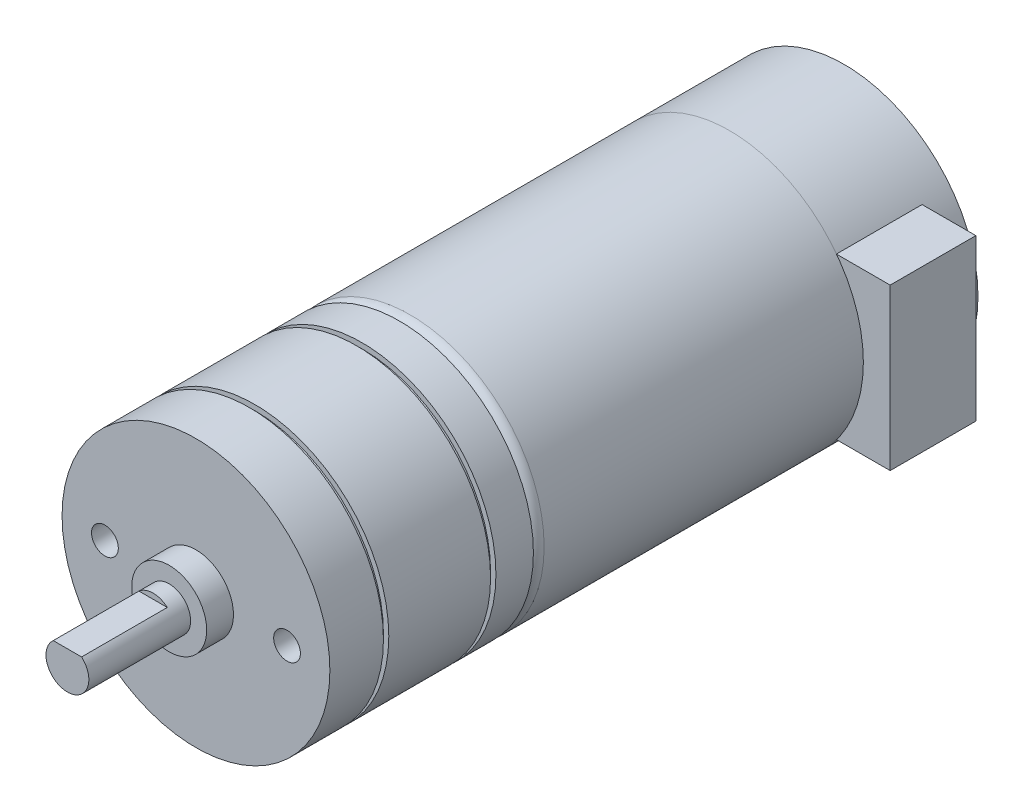
from build123d import *

# Parameters (mm, degrees)
SKETCH_1_R             = 12.5
EXTRUDE_1_DEPTH        = 30.8
SKETCH_2_R             = 12.5
EXTRUDE_2_DEPTH        = 10.7
SKETCH_3_W             = 8
SKETCH_3_H             = 15
EXTRUDE_3_DEPTH        = 15
FILLET_1_R             = 1
SKETCH_4_R             = 12.5
EXTRUDE_4_DEPTH        = 19
CUT_EXTRUDE_START      = -15
SKETCH_5_R             = 12.5
SKETCH_5_R_2           = 12
CUT_EXTRUDE_1_DEPTH    = 0.5
PATTERN_LINEAR_1_COUNT = 2
PATTERN_LINEAR_1_PITCH = 10
SKETCH_6_R             = 3.5
EXTRUDE_5_DEPTH        = 2.5
SKETCH_7_R             = 2
EXTRUDE_6_DEPTH        = 9.5
CUT_EXTRUDE_2_DEPTH    = 8
M3X0_5_1_AT_2_COUNT    = 2
M3X0_5_1_AT_2_PITCH    = 17


with BuildPart() as part:
    # 草圖1 → 填料-伸長1 (new body)
    with BuildSketch(Plane.XY):
        Circle(SKETCH_1_R)
    extrude(amount=EXTRUDE_1_DEPTH)

    # 圓角1
    fillet_1_edges = [part.edges().sort_by_distance(p)[0] for p in [
        (-12.5, 0, 30.8),
    ]]
    fillet(fillet_1_edges, radius=FILLET_1_R)


with BuildPart() as body_2:
    # 草圖2 → 填料-伸長2 (new body)
    with BuildSketch(Plane(origin=(0, 0, 0), x_dir=(-1, 0, 0), z_dir=(0, 0, -1))):
        Circle(SKETCH_2_R)
    extrude(amount=EXTRUDE_2_DEPTH)


with BuildPart() as body_3:
    # 草圖3 → 填料-伸長3 (new body)
    with BuildSketch(Plane(origin=(0, 0, 0), x_dir=(0, 0, -1), z_dir=(1, 0, 0))):
        with Locations((4, 0)):
            Rectangle(SKETCH_3_W, SKETCH_3_H)
    extrude(amount=EXTRUDE_3_DEPTH)


with BuildPart() as body_4:
    # 草圖4 → 填料-伸長4 (new body)
    with BuildSketch(Plane.XY.offset(30.8)):
        Circle(SKETCH_4_R)
    extrude(amount=EXTRUDE_4_DEPTH)

    # 草圖5 → 除料-伸長1 (cut)
    with BuildSketch(Plane.XY.offset(49.8).offset(CUT_EXTRUDE_START)):
        Circle(SKETCH_5_R)
        Circle(SKETCH_5_R_2, mode=Mode.SUBTRACT)
    cut_extrude_1 = extrude(amount=-CUT_EXTRUDE_1_DEPTH, mode=Mode.SUBTRACT)

    # 直線複製排列1: 除料-伸長1 ×2
    with Locations(*[(0, 0, i * PATTERN_LINEAR_1_PITCH) for i in range(1, PATTERN_LINEAR_1_COUNT)]):
        add(cut_extrude_1, mode=Mode.SUBTRACT)

    # 草圖12 → M3x0.5 螺紋孔1 (revolve, cut)
    with BuildSketch(Plane(origin=(8.5, 0, 49.8), x_dir=(0, -1, 0), z_dir=(1, 0, 0))):
        Polygon((0, 0), (0, 5.751075774), (1.25, 5), (1.25, 0), align=None)
    m3x0_5_1 = revolve(axis=Axis((8.5, 0, 56.15), (0, 0, -1)), mode=Mode.SUBTRACT)

    # M3x0.5 螺紋孔1 at 2: M3x0.5 螺紋孔1 ×2
    with Locations(*[(-i * M3X0_5_1_AT_2_PITCH, 0, 0) for i in range(1, M3X0_5_1_AT_2_COUNT)]):
        add(m3x0_5_1, mode=Mode.SUBTRACT)


with BuildPart() as body_5:
    # 草圖6 → 填料-伸長5 (new body)
    with BuildSketch(Plane.XY.offset(49.8)):
        Circle(SKETCH_6_R)
    extrude(amount=EXTRUDE_5_DEPTH)

    # 草圖7 → 填料-伸長6 (add)
    with BuildSketch(Plane.XY.offset(52.3)):
        Circle(SKETCH_7_R)
    extrude(amount=EXTRUDE_6_DEPTH)

    # 草圖8 → 除料-伸長2 (cut)
    with BuildSketch(Plane.XY.offset(61.8)):
        with BuildLine():
            Line((-1.322875656, 1.5), (1.322875656, 1.5))
            ThreePointArc((1.322875656, 1.5), (0, 2), (-1.322875656, 1.5))
        make_face()
    extrude(amount=-CUT_EXTRUDE_2_DEPTH, mode=Mode.SUBTRACT)


solid = Compound([part.part, body_2.part, body_3.part, body_4.part, body_5.part])
